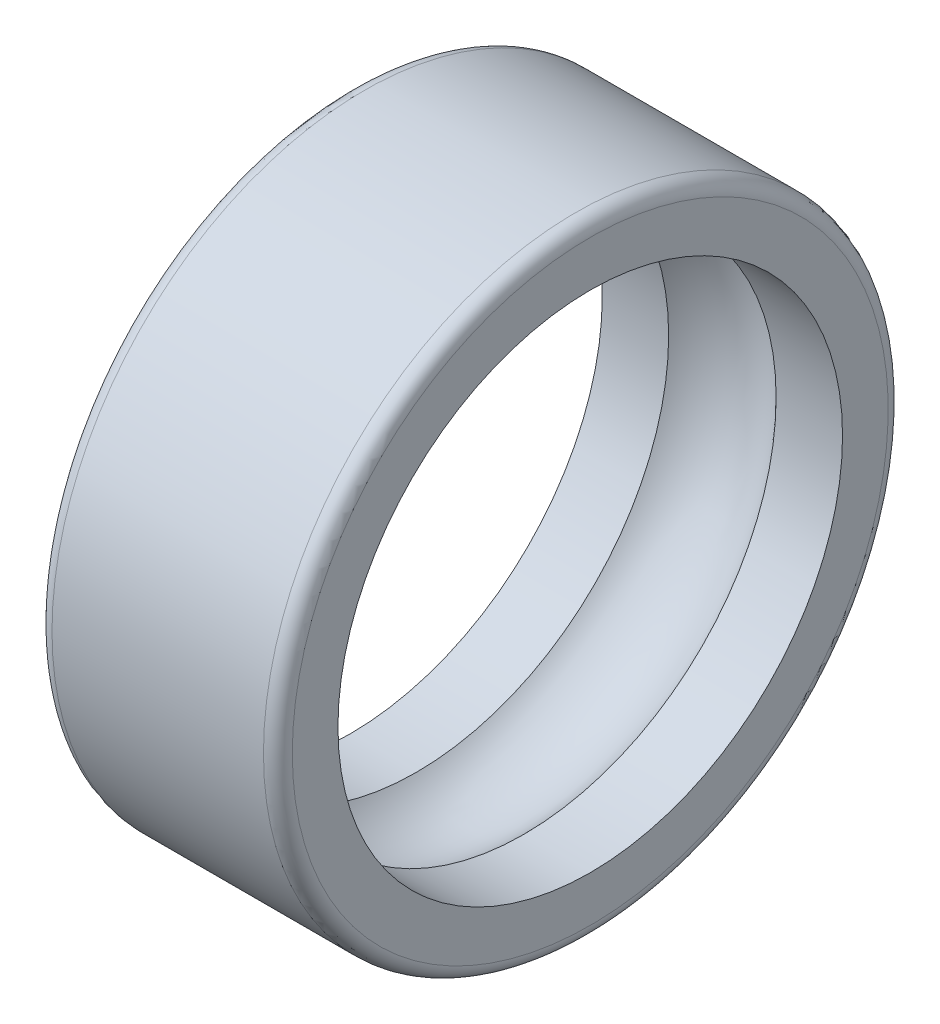
from build123d import *

# Parameters (mm, degrees)
CONG_1_R = 0.3


with BuildPart() as part:
    # Esquisse1 → Base-Révolution (revolve)
    with BuildSketch(Plane.XY):
        with BuildLine():
            Line((0, 5.25), (1.381966011, 5.25))
            ThreePointArc((1.381966011, 5.25), (2.5, 5.75), (3.618033989, 5.25))
            Line((3.618033989, 5.25), (5, 5.25))
            Line((5, 5.25), (5, 6.5))
            Line((5, 6.5), (0, 6.5))
            Line((0, 6.5), (0, 5.25))
        make_face()
    revolve(axis=Axis((0, 0, 0), (1, 0, 0)))

    # Congé1
    cong_1_edges = [part.edges().sort_by_distance(p)[0] for p in [
        (5, -6.5, 0),
        (0, -6.5, 0),
    ]]
    fillet(cong_1_edges, radius=CONG_1_R)


solid = part.part
